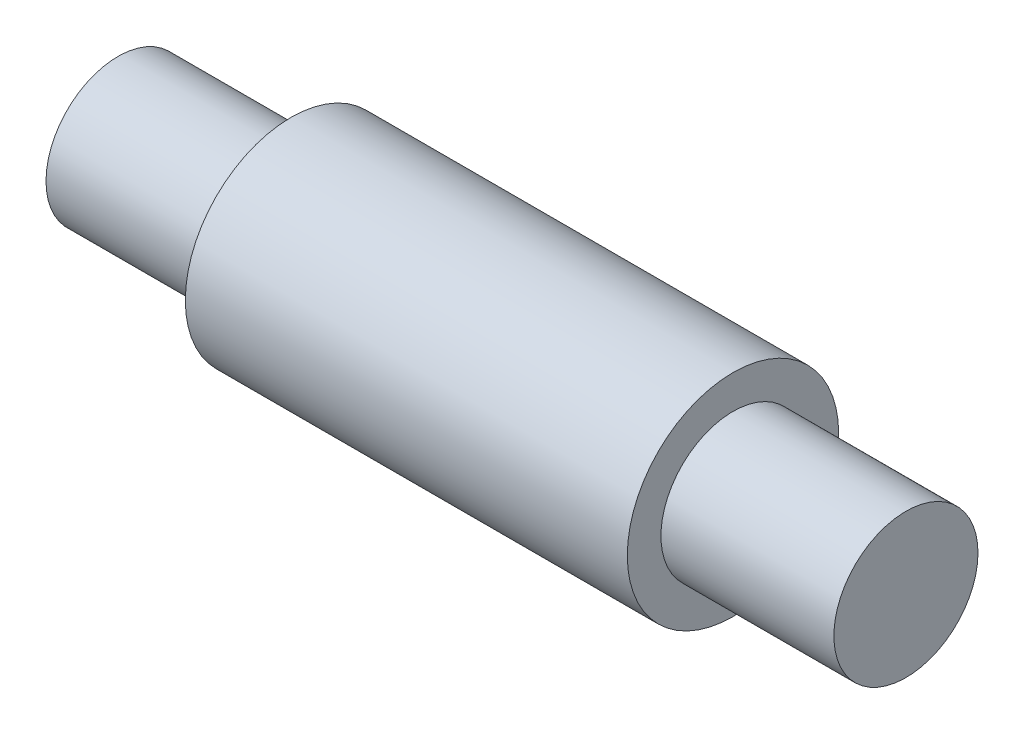
from build123d import *

# Parameters (mm, degrees)
SKETCH1_R           = 11
BOSS_EXTRUDE1_DEPTH = 46
SKETCH2_R           = 7.5
BOSS_EXTRUDE2_DEPTH = 18
SKETCH3_R           = 7.5
BOSS_EXTRUDE3_DEPTH = 18


with BuildPart() as part:
    # Sketch1 → Boss-Extrude1 (new body)
    with BuildSketch(Plane(origin=(0, 0, 0), x_dir=(0, 0, -1), z_dir=(1, 0, 0))):
        Circle(SKETCH1_R)
    extrude(amount=BOSS_EXTRUDE1_DEPTH)

    # Sketch2 → Boss-Extrude2 (add)
    with BuildSketch(Plane(origin=(46, 0, 0), x_dir=(0, 0, -1), z_dir=(1, 0, 0))):
        Circle(SKETCH2_R)
    extrude(amount=BOSS_EXTRUDE2_DEPTH)

    # Sketch3 → Boss-Extrude3 (add)
    with BuildSketch(Plane.ZY):
        Circle(SKETCH3_R)
    extrude(amount=BOSS_EXTRUDE3_DEPTH)


solid = part.part
